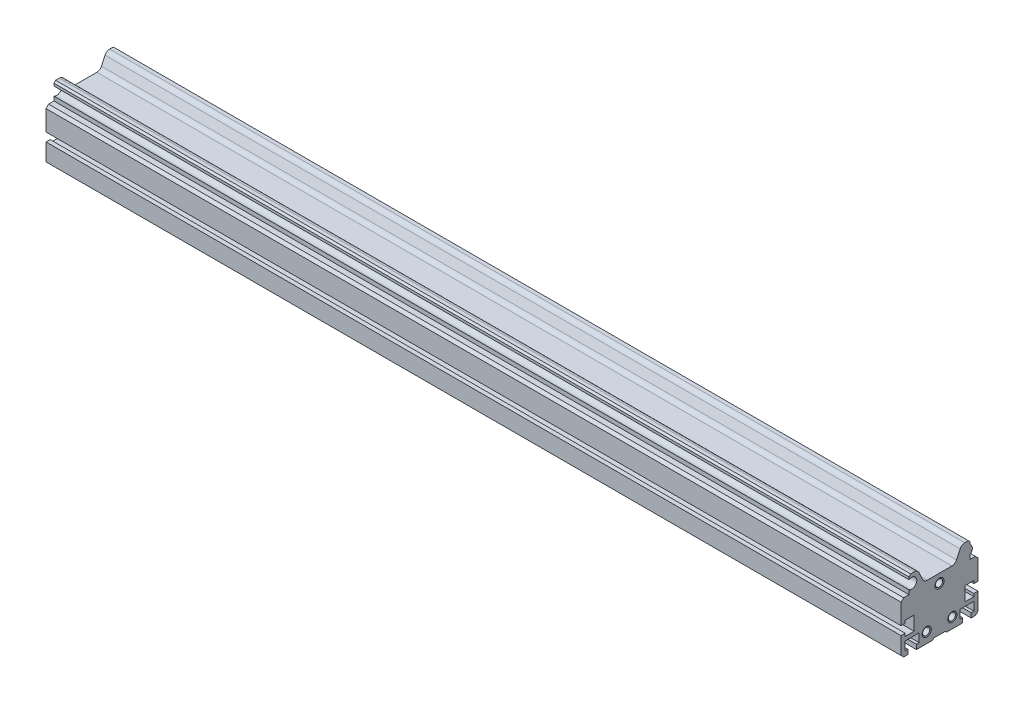
from build123d import *

# Parameters (mm, degrees)
EXTRUDE_1_DEPTH                = 500
SKETCH_2_W                     = 500
SKETCH_2_H                     = 30
EXTRUDE_2_DEPTH                = 4.65
CUT_EXTRUDE_1_DEPTH            = 501
CUT_EXTRUDE_2_DEPTH            = 501
SKETCH_5_W                     = 6.7
SKETCH_5_H                     = 0.8
CUT_EXTRUDE_3_DEPTH            = 501
CUT_EXTRUDE_4_DEPTH            = 501
CUT_EXTRUDE_5_DEPTH            = 501
CUT_EXTRUDE_6_DEPTH            = 501
SKETCH_9_W                     = 18.238994336
SKETCH_9_H                     = 8
CUT_EXTRUDE_7_DEPTH            = 501
DRAFT_1_ANGLE                  = 45
DRAFT_2_ANGLE                  = 24.775140569
F_4_2_4_2_DIAMETER_HOLE1_D     = 4.2
F_4_2_4_2_DIAMETER_HOLE1_DEPTH = 500
F_6_0_6_DIAMETER_HOLE1_D       = 6
F_6_0_6_DIAMETER_HOLE1_DEPTH   = 500
CHAMFER_1_SIZE                 = 0.6
CHAMFER_1_SIZE2                = 0.279784595
CHAMFER_2_SIZE                 = 0.6
CHAMFER_3_SIZE                 = 1
CHAMFER_4_SIZE                 = 1.5
FILLET_1_R                     = 3


with BuildPart() as part:
    # 스케치1 → 보스-돌출1 (new body)
    with BuildSketch(Plane(origin=(400, 0, 0), x_dir=(0, 0, -1), z_dir=(1, 0, 0))):
        Polygon((-17.85, 38.2), (-17.85, -0.8), (22.5, -0.8), (22.5, 39.2), (-16.85, 39.2), align=None)
    extrude(amount=-EXTRUDE_1_DEPTH)

    # 스케치2 → 보스-돌출2 (add)
    with BuildSketch(Plane.XY.offset(17.85)):
        with Locations((150, 14.2)):
            Rectangle(SKETCH_2_W, SKETCH_2_H)
    extrude(amount=EXTRUDE_2_DEPTH)

    # 스케치3 → 컷-돌출1 (cut, through all)
    with BuildSketch(Plane.ZY.offset(100)):
        Polygon((22.5, 10.8), (22.5, 15.8), (20.1, 15.8), (20.1, 17.4), (14.9, 17.4), (14.9, 9.2), (20.1, 9.2), (20.1, 10.8), align=None)
    extrude(amount=-CUT_EXTRUDE_1_DEPTH, mode=Mode.SUBTRACT)

    # 스케치4 → 컷-돌출2 (cut, through all)
    with BuildSketch(Plane.ZY.offset(100)):
        Polygon((13.5, -0.8), (18.5, -0.8), (18.5, 1.9), (20.1, 1.9), (20.1, 6.9), (11.9, 6.9), (11.9, 1.9), (13.5, 1.9), align=None)
    extrude(amount=-CUT_EXTRUDE_2_DEPTH, mode=Mode.SUBTRACT)

    # 스케치5 → 컷-돌출3 (cut, through all)
    with BuildSketch(Plane.ZY.offset(100)):
        with Locations((0, -0.4)):
            Rectangle(SKETCH_5_W, SKETCH_5_H)
    extrude(amount=-CUT_EXTRUDE_3_DEPTH, mode=Mode.SUBTRACT)

    # 스케치6 → 컷-돌출4 (cut, through all)
    with BuildSketch(Plane.ZY.offset(100)):
        Polygon((-18.5, -0.8), (-13.5, -0.8), (-13.5, 1.9), (-11.9, 1.9), (-11.9, 6.9), (-20.1, 6.9), (-20.1, 1.9), (-18.5, 1.9), align=None)
    extrude(amount=-CUT_EXTRUDE_4_DEPTH, mode=Mode.SUBTRACT)

    # 스케치7 → 컷-돌출5 (cut, through all)
    with BuildSketch(Plane.ZY.offset(100)):
        Polygon((-22.5, 15.8), (-22.5, 10.8), (-20.1, 10.8), (-20.1, 9.2), (-14.9, 9.2), (-14.9, 17.4), (-20.1, 17.4), (-20.1, 15.8), align=None)
    extrude(amount=-CUT_EXTRUDE_5_DEPTH, mode=Mode.SUBTRACT)

    # 스케치8 → 컷-돌출6 (cut, through all)
    with BuildSketch(Plane.ZY.offset(100)):
        with BuildLine():
            Line((-17.85, 36.705493963), (-17.85, 39.2))
            Line((-17.85, 39.2), (-22.5, 39.2))
            Line((-22.5, 39.2), (-22.5, 29.2))
            Line((-22.5, 29.2), (-17.85, 29.2))
            Line((-17.85, 29.2), (-17.85, 31.694506037))
            ThreePointArc((-17.85, 31.694506037), (-19.2, 34.2), (-17.85, 36.705493963))
        make_face()
    extrude(amount=-CUT_EXTRUDE_6_DEPTH, mode=Mode.SUBTRACT)

    # 스케치9 → 컷-돌출7 (cut, through all)
    with BuildSketch(Plane.ZY.offset(100)):
        with Locations((0, 35.2)):
            Rectangle(SKETCH_9_W, SKETCH_9_H)
    extrude(amount=-CUT_EXTRUDE_7_DEPTH, mode=Mode.SUBTRACT)

    # 구배1
    draft_1_faces = [part.faces().sort_by_distance(p)[0] for p in [
        (150, -0.4, 3.35),
        (150, -0.4, -3.35),
    ]]
    draft(draft_1_faces, Plane(origin=(400, 0, 3.35), x_dir=(0, 0, -1), z_dir=(0, -1, 0)), DRAFT_1_ANGLE)

    # 구배2
    draft_2_faces = [part.faces().sort_by_distance(p)[0] for p in [
        (150, 35.2, 9.119497168),
        (150, 35.2, -9.119497168),
    ]]
    draft(draft_2_faces, Plane(origin=(400, 31.2, -9.119497168), x_dir=(0, 0, 1), z_dir=(0, 1, 0)), DRAFT_2_ANGLE)

    # Ø4.2 (4.2) Diameter Hole1
    with Locations(Plane(origin=(400, 0, 0), x_dir=(0, 0, -1), z_dir=(1, 0, 0))):
        with Locations((-7.5, 5.25), (7.5, 5.25), (0, 26)):
            Hole(F_4_2_4_2_DIAMETER_HOLE1_D / 2, depth=F_4_2_4_2_DIAMETER_HOLE1_DEPTH)

    # Ø6.0 (6) Diameter Hole1
    with Locations(Plane.ZY.offset(100)):
        with Locations((16.290651015, 34.2)):
            Hole(F_6_0_6_DIAMETER_HOLE1_D / 2, depth=F_6_0_6_DIAMETER_HOLE1_DEPTH)

    # 모따기1
    chamfer_1_edges = [part.edges().sort_by_distance(p)[0] for p in [
        (400, 26, -2.1),
        (400, 5.25, -9.6),
        (400, 5.25, 5.4),
    ]]
    chamfer_1_side = [part.faces().sort_by_distance(p)[0] for p in [
        (400, 17.793427641, -0.369480422),
    ]]
    chamfer(chamfer_1_edges, length=CHAMFER_1_SIZE, length2=CHAMFER_1_SIZE2, reference=chamfer_1_side[0])

    # 모따기2
    chamfer_2_edges = [part.edges().sort_by_distance(p)[0] for p in [
        (-100, 26, -2.1),
        (-100, 5.25, -9.6),
        (-100, 5.25, 5.4),
    ]]
    chamfer(chamfer_2_edges, length=CHAMFER_2_SIZE)

    # 모따기3
    chamfer_3_edges = [part.edges().sort_by_distance(p)[0] for p in [
        (150, 39.2, -17.85),
    ]]
    chamfer(chamfer_3_edges, length=CHAMFER_3_SIZE)

    # 모따기4
    chamfer_4_edges = [part.edges().sort_by_distance(p)[0] for p in [
        (150, 29.2, -22.5),
        (150, 29.2, 22.5),
        (150, -0.8, 22.5),
        (150, -0.8, -22.5),
    ]]
    chamfer(chamfer_4_edges, length=CHAMFER_4_SIZE)

    # 필렛1
    fillet_1_edges = [part.edges().sort_by_distance(p)[0] for p in [
        (150, 39.2, -12.811804861),
        (150, 39.2, 12.811804861),
        (150, 31.2, 9.119497168),
        (150, 31.2, -9.119497168),
    ]]
    fillet(fillet_1_edges, radius=FILLET_1_R)


solid = part.part
